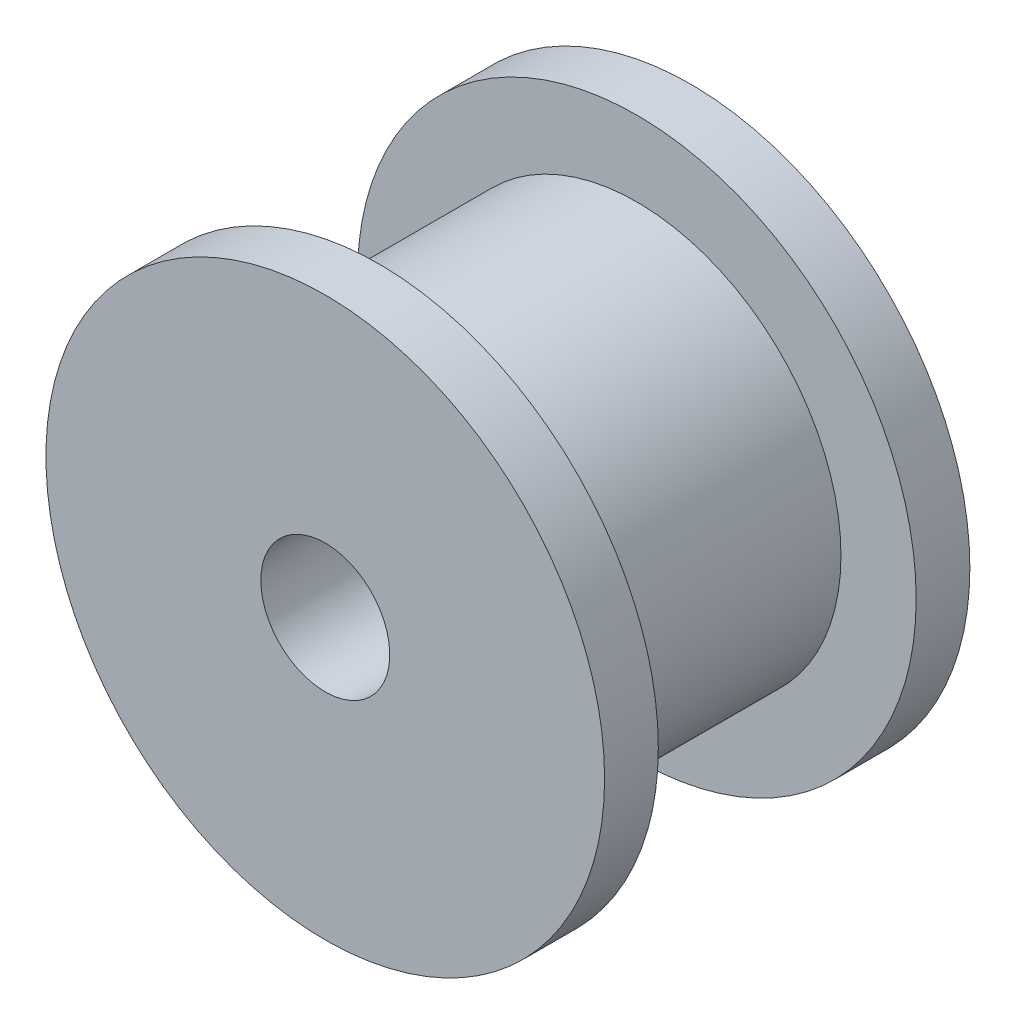
from build123d import *

# Parameters (mm, degrees)
SKETCH_1_R          = 6.5
EXTRUDE_1_DEPTH     = 1.25
SKETCH_2_R          = 4.75
EXTRUDE_2_DEPTH     = 6
SKETCH_3_R          = 6.5
EXTRUDE_3_DEPTH     = 1.25
SKETCH_4_R          = 1.5
CUT_EXTRUDE_1_DEPTH = 9.5


with BuildPart() as part:
    # 草图1 → 凸台-拉伸1 (new body)
    with BuildSketch(Plane.XY):
        Circle(SKETCH_1_R)
    extrude(amount=EXTRUDE_1_DEPTH)

    # 草图2 → 凸台-拉伸2 (add)
    with BuildSketch(Plane.XY.offset(1.25)):
        Circle(SKETCH_2_R)
    extrude(amount=EXTRUDE_2_DEPTH)

    # 草图3 → 凸台-拉伸3 (add)
    with BuildSketch(Plane.XY.offset(7.25)):
        Circle(SKETCH_3_R)
    extrude(amount=EXTRUDE_3_DEPTH)

    # 草图4 → 切除-拉伸1 (cut, through all)
    with BuildSketch(Plane(origin=(0, 0, 0), x_dir=(-1, 0, 0), z_dir=(0, 0, -1))):
        Circle(SKETCH_4_R)
    extrude(amount=-CUT_EXTRUDE_1_DEPTH, mode=Mode.SUBTRACT)


solid = part.part
